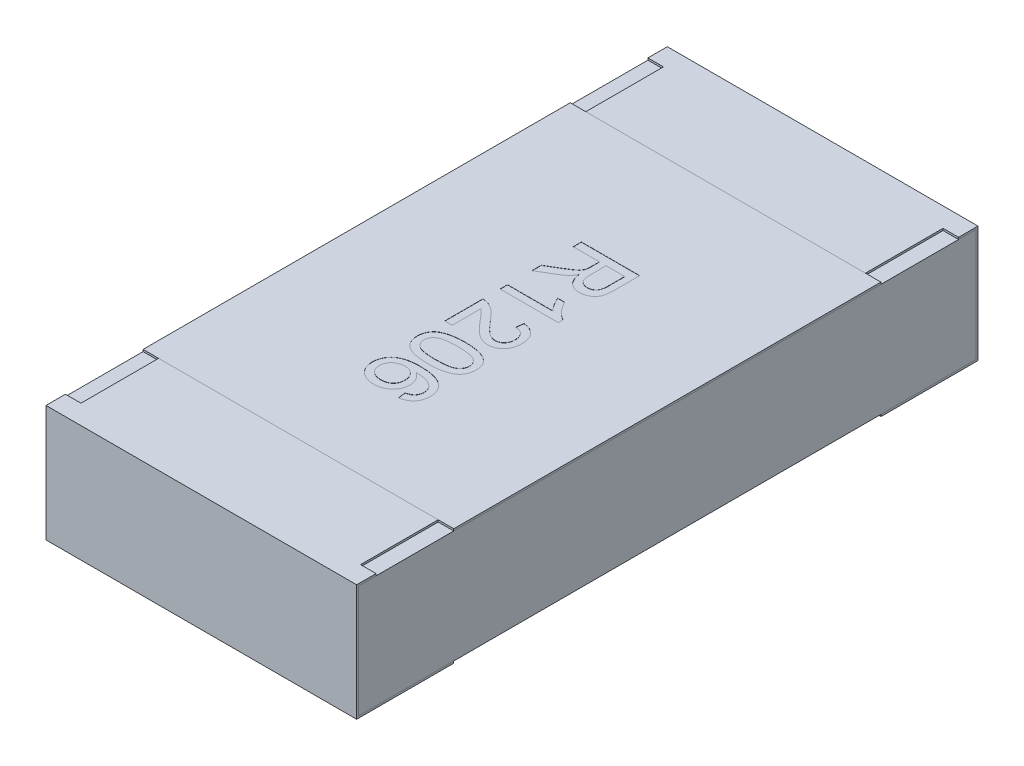
from build123d import *

# Parameters (mm, degrees)
BOSS_EXTRUDE2_DEPTH   = 0.8
BOSS_EXTRUDE2_2_DEPTH = 0.8
BOSS_EXTRUDE3_START   = -0.8
SKETCH5_W             = 3.18
SKETCH5_H             = 0.58
BOSS_EXTRUDE3_DEPTH   = 1.6
SKETCH6_W             = 0.08
SKETCH6_H             = 0.4
CUT_EXTRUDE1_DEPTH    = 0.01
SKETCH7_W             = 1.6
SKETCH7_H             = 2.2
BOSS_EXTRUDE4_DEPTH   = 0.01
TEXT1206_DEPTH        = 0.001


with BuildPart() as part:
    # Sketch4 → Boss-Extrude2 (new body, symmetric)
    with BuildSketch(Plane(origin=(0, 0, 0), x_dir=(0, 0, -1), z_dir=(1, 0, 0))):
        Polygon((-1.6, 0.3), (-1.6, -0.3), (-1.1, -0.3), (-1.1, -0.29), (-1.59, -0.29), (-1.59, 0.29), (-1.1, 0.29), (-1.1, 0.3), align=None)
    extrude(amount=BOSS_EXTRUDE2_DEPTH, both=True)


with BuildPart() as body_2:
    # Sketch4 → Boss-Extrude2 2 (new body, symmetric)
    with BuildSketch(Plane(origin=(0, 0, 0), x_dir=(0, 0, -1), z_dir=(1, 0, 0))):
        Polygon((1.1, 0.3), (1.6, 0.3), (1.6, -0.3), (1.1, -0.3), (1.1, -0.29), (1.59, -0.29), (1.59, 0.29), (1.1, 0.29), align=None)
    extrude(amount=BOSS_EXTRUDE2_2_DEPTH, both=True)


with BuildPart() as body_3:
    # Sketch5 → Boss-Extrude3 (new body)
    with BuildSketch(Plane(origin=(0, 0, 0), x_dir=(0, 0, -1), z_dir=(1, 0, 0)).offset(BOSS_EXTRUDE3_START)):
        Rectangle(SKETCH5_W, SKETCH5_H)
    extrude(amount=BOSS_EXTRUDE3_DEPTH)


with BuildPart() as cut_extrude1_tool:
    # Sketch6 → Cut-Extrude1 (new body)
    with BuildSketch(Plane(origin=(0, 0.3, 0), x_dir=(1, 0, 0), z_dir=(0, 1, 0))):
        with Locations((-0.76, 1.3)):
            Rectangle(SKETCH6_W, SKETCH6_H)
        with Locations((0.76, 1.3)):
            Rectangle(SKETCH6_W, SKETCH6_H)
        with Locations((0.76, -1.3)):
            Rectangle(SKETCH6_W, SKETCH6_H)
        with Locations((-0.76, -1.3)):
            Rectangle(SKETCH6_W, SKETCH6_H)
    extrude(amount=-CUT_EXTRUDE1_DEPTH)


with BuildPart() as part_1:
    add(part.part)

    # Cut-Extrude1: cut by cut_extrude1_tool
    add(cut_extrude1_tool.part, mode=Mode.SUBTRACT)


with BuildPart() as body_2_1:
    add(body_2.part)

    # Cut-Extrude1: cut by cut_extrude1_tool
    add(cut_extrude1_tool.part, mode=Mode.SUBTRACT)


with BuildPart() as body_4:
    # Sketch7 → Boss-Extrude4 (new body)
    with BuildSketch(Plane(origin=(0, 0.29, 0), x_dir=(1, 0, 0), z_dir=(0, 1, 0))):
        Rectangle(SKETCH7_W, SKETCH7_H)
    extrude(amount=BOSS_EXTRUDE4_DEPTH)

    # Sketch12 → TEXT1206 (cut)
    with BuildSketch(Plane(origin=(0, 0.3, 0), x_dir=(1, 0, 0), z_dir=(0, 1, 0))):
        with BuildLine():
            Line((-0.15, 0.507688704), (0.15, 0.507688704))
            Line((0.15, 0.507688704), (0.15, 0.377520435))
            add(Edge.make_bspline(
                [(0.15, 0.377520435), (0.149976098, 0.374455356), (0.149929838, 0.368523255), (0.149599275, 0.359920721), (0.148896994, 0.351910091), (0.148112632, 0.344440878), (0.146954506, 0.337525862), (0.145595815, 0.331161748), (0.14399, 0.325372947), (0.142091864, 0.320115402), (0.139945096, 0.315237172), (0.137294925, 0.310716634), (0.134395694, 0.306360041), (0.130961971, 0.302339737), (0.12726979, 0.29847974), (0.123136626, 0.294911955), (0.118620847, 0.29161897), (0.112164906, 0.28755572), (0.103522968, 0.283280255), (0.092520499, 0.279631156), (0.080987257, 0.277298105), (0.073108187, 0.277046918), (0.069110577, 0.276919473)],
                knots=[0, 0, 0, 0, 9.195e-06, 1.7797e-05, 2.5817e-05, 3.3316e-05, 4.0321e-05, 4.6839e-05, 5.2832e-05, 5.8326e-05, 6.3598e-05, 6.8794e-05, 7.4028e-05, 7.9275e-05, 8.463e-05, 9.0041e-05, 9.563e-05, 0.000101382, 0.000112912, 0.000124447, 0.00013608, 0.000148061, 0.000148061, 0.000148061, 0.000148061], degree=3))
            add(Edge.make_bspline(
                [(0.069110577, 0.276919473), (0.066544329, 0.276978179), (0.061475814, 0.277094125), (0.054023732, 0.277982277), (0.046903597, 0.27958935), (0.040052911, 0.281649992), (0.033569258, 0.284470798), (0.027318263, 0.287737107), (0.021478898, 0.291789228), (0.015856738, 0.296313931), (0.010702727, 0.301574208), (0.00594759, 0.30742974), (0.001839276, 0.314027897), (-0.001852779, 0.321247263), (-0.005083582, 0.329100938), (-0.007800008, 0.337641146), (-0.009926689, 0.346837648), (-0.010991982, 0.353215196), (-0.011538462, 0.356486781)],
                knots=[0, 0, 0, 0, 7.698e-06, 1.5204e-05, 2.2466e-05, 2.9575e-05, 3.663e-05, 4.3647e-05, 5.0697e-05, 5.7915e-05, 6.5267e-05, 7.2747e-05, 8.05e-05, 8.8536e-05, 9.7051e-05, 0.000105946, 0.000115392, 0.000125341, 0.000125341, 0.000125341, 0.000125341], degree=3))
            add(Edge.make_bspline(
                [(-0.011538462, 0.356486781), (-0.012753772, 0.35406856), (-0.01505392, 0.349491732), (-0.018746634, 0.343178787), (-0.022400996, 0.337757739), (-0.025073191, 0.334630892), (-0.026322115, 0.333169473)],
                knots=[0, 0, 0, 0, 8.117e-06, 1.5363e-05, 2.1931e-05, 2.7694e-05, 2.7694e-05, 2.7694e-05, 2.7694e-05], degree=3))
            add(Edge.make_bspline(
                [(-0.026322115, 0.333169473), (-0.029096413, 0.330330674), (-0.034786041, 0.324508765), (-0.044567018, 0.31656401), (-0.055323294, 0.308702769), (-0.06316159, 0.303983044), (-0.0671875, 0.301558896)],
                knots=[0, 0, 0, 0, 1.1899e-05, 2.4402e-05, 3.7746e-05, 5.1837e-05, 5.1837e-05, 5.1837e-05, 5.1837e-05], degree=3))
            Line((-0.0671875, 0.301558896), (-0.15, 0.252340146))
            Line((-0.15, 0.252340146), (-0.15, 0.300837743))
            Line((-0.15, 0.300837743), (-0.086658654, 0.33821755))
            add(Edge.make_bspline(
                [(-0.086658654, 0.33821755), (-0.084436284, 0.339561596), (-0.080129696, 0.342166135), (-0.073839518, 0.345927393), (-0.068050631, 0.349618517), (-0.062587585, 0.353030789), (-0.057592425, 0.356346736), (-0.052916134, 0.359380146), (-0.048743568, 0.362364404), (-0.043718189, 0.365835136), (-0.038248453, 0.370019606), (-0.03266463, 0.374935646), (-0.028105288, 0.379497197), (-0.02370073, 0.385204319), (-0.019596578, 0.392286081), (-0.017689234, 0.398293218), (-0.016766827, 0.401198319)],
                knots=[0, 0, 0, 0, 7.792e-06, 1.5099e-05, 2.1985e-05, 2.8387e-05, 3.4421e-05, 3.9972e-05, 4.5107e-05, 4.9808e-05, 5.8294e-05, 6.5746e-05, 7.212e-05, 7.7602e-05, 8.7344e-05, 9.6468e-05, 9.6468e-05, 9.6468e-05, 9.6468e-05], degree=3))
            add(Edge.make_bspline(
                [(-0.016766827, 0.401198319), (-0.016546925, 0.402417733), (-0.016044883, 0.405201691), (-0.015716998, 0.409928844), (-0.015368993, 0.415656371), (-0.015379133, 0.419807207), (-0.015384615, 0.422051685)],
                knots=[0, 0, 0, 0, 3.715e-06, 8.481e-06, 1.4198e-05, 2.0929e-05, 2.0929e-05, 2.0929e-05, 2.0929e-05], degree=3))
            Line((-0.015384615, 0.422051685), (-0.015384615, 0.465381012))
            Line((-0.015384615, 0.465381012), (-0.15, 0.465381012))
            Line((-0.15, 0.465381012), (-0.15, 0.507688704))
        make_face()
        with BuildLine():
            Line((0.019230769, 0.465381012), (0.019230769, 0.385032454))
            add(Edge.make_bspline(
                [(0.019230769, 0.385032454), (0.019294059, 0.381003526), (0.019412374, 0.373471823), (0.020415568, 0.36293915), (0.022027239, 0.353946653), (0.02434032, 0.346326486), (0.027566204, 0.339927885), (0.031574247, 0.334430884), (0.036450959, 0.329754481), (0.042058536, 0.325932572), (0.048176988, 0.322922341), (0.054649472, 0.320867375), (0.061335975, 0.319435692), (0.06589779, 0.31929729), (0.068209135, 0.319227166)],
                knots=[0, 0, 0, 0, 1.2085e-05, 2.2591e-05, 3.1702e-05, 3.9457e-05, 4.6391e-05, 5.3098e-05, 5.9771e-05, 6.6555e-05, 7.3382e-05, 8.0147e-05, 8.6889e-05, 9.3813e-05, 9.3813e-05, 9.3813e-05, 9.3813e-05], degree=3))
            add(Edge.make_bspline(
                [(0.068209135, 0.319227166), (0.069893078, 0.319283004), (0.073191429, 0.319392375), (0.078032493, 0.319965732), (0.082632622, 0.321080474), (0.087016134, 0.322552489), (0.091150922, 0.3245194), (0.095069027, 0.32685601), (0.098748733, 0.329644306), (0.102201249, 0.33283814), (0.1053427, 0.336505241), (0.108053092, 0.340693932), (0.11035634, 0.345371178), (0.112184352, 0.350542415), (0.113646463, 0.356191353), (0.114619159, 0.36235015), (0.115322998, 0.36899064), (0.115363693, 0.373592114), (0.115384615, 0.375957935)],
                knots=[0, 0, 0, 0, 5.054e-06, 9.899e-06, 1.4593e-05, 1.923e-05, 2.3746e-05, 2.8302e-05, 3.2893e-05, 3.757e-05, 4.2387e-05, 4.7338e-05, 5.2498e-05, 5.7992e-05, 6.3764e-05, 6.9978e-05, 7.6682e-05, 8.3775e-05, 8.3775e-05, 8.3775e-05, 8.3775e-05], degree=3))
            Line((0.115384615, 0.375957935), (0.115384615, 0.465381012))
            Line((0.115384615, 0.465381012), (0.019230769, 0.465381012))
        make_face(mode=Mode.SUBTRACT)
        with BuildLine():
            Line((-0.15, 0.088457935), (-0.15, 0.126919473))
            Line((-0.15, 0.126919473), (0.083774038, 0.126919473))
            add(Edge.make_bspline(
                [(0.083774038, 0.126919473), (0.081638509, 0.129134219), (0.077200045, 0.133737325), (0.070914564, 0.141515786), (0.064571645, 0.150195638), (0.058389404, 0.159632893), (0.052683492, 0.169326831), (0.047476916, 0.178666395), (0.043093554, 0.187521136), (0.040694469, 0.193352207), (0.039543269, 0.196150243)],
                knots=[0, 0, 0, 0, 9.226e-06, 1.9175e-05, 2.9969e-05, 4.147e-05, 5.3003e-05, 6.3709e-05, 7.3546e-05, 8.262e-05, 8.262e-05, 8.262e-05, 8.262e-05], degree=3))
            Line((0.039543269, 0.196150243), (0.075, 0.196150243))
            add(Edge.make_bspline(
                [(0.075, 0.196150243), (0.077475162, 0.191344122), (0.082353558, 0.181871544), (0.09077922, 0.168488839), (0.099912985, 0.155994644), (0.10975283, 0.144595788), (0.119810917, 0.13437744), (0.129959923, 0.12576629), (0.139827828, 0.118561027), (0.146709597, 0.11494601), (0.15, 0.11321755)],
                knots=[0, 0, 0, 0, 1.6212e-05, 3.1953e-05, 4.7386e-05, 6.26e-05, 7.7091e-05, 9.0349e-05, 0.000102505, 0.000113642, 0.000113642, 0.000113642, 0.000113642], degree=3))
            Line((0.15, 0.11321755), (0.15, 0.088457935))
            Line((0.15, 0.088457935), (-0.15, 0.088457935))
        make_face()
        with BuildLine():
            Line((-0.111538462, -0.19615745), (-0.15, -0.19615745))
            Line((-0.15, -0.19615745), (-0.15, -3.604e-06))
            add(Edge.make_bspline(
                [(-0.15, -3.604e-06), (-0.147714123, 4.12e-07), (-0.14315003, 8.43e-06), (-0.136400026, -0.000763888), (-0.129739566, -0.001973492), (-0.125468478, -0.003341192), (-0.123317308, -0.004030046)],
                knots=[0, 0, 0, 0, 6.852e-06, 1.3681e-05, 2.0352e-05, 2.7121e-05, 2.7121e-05, 2.7121e-05, 2.7121e-05], degree=3))
            add(Edge.make_bspline(
                [(-0.123317308, -0.004030046), (-0.119803316, -0.005304062), (-0.112648251, -0.00789817), (-0.102300861, -0.013133764), (-0.092077121, -0.019394304), (-0.083693742, -0.025385777), (-0.077044802, -0.03090393), (-0.071780052, -0.035454388), (-0.066458477, -0.040580386), (-0.06098519, -0.04618848), (-0.055359875, -0.052244636), (-0.049556317, -0.058748619), (-0.043684824, -0.065779698), (-0.039792869, -0.070688025), (-0.037800481, -0.073200719)],
                knots=[0, 0, 0, 0, 1.1205e-05, 2.2816e-05, 3.4709e-05, 4.7152e-05, 5.3684e-05, 6.0627e-05, 6.8023e-05, 7.5842e-05, 8.4134e-05, 9.2818e-05, 0.00010199, 0.00011161, 0.00011161, 0.00011161, 0.00011161], degree=3))
            add(Edge.make_bspline(
                [(-0.037800481, -0.073200719), (-0.034551471, -0.077060851), (-0.028295295, -0.084493779), (-0.019011711, -0.094990239), (-0.010391377, -0.104577047), (-0.002283205, -0.113101543), (0.005234162, -0.120633449), (0.012143692, -0.127190451), (0.018423822, -0.132828966), (0.024301865, -0.137480159), (0.029852373, -0.141404514), (0.035266551, -0.144730057), (0.040638972, -0.147501457), (0.045952637, -0.149809662), (0.05123027, -0.151635256), (0.056487246, -0.152879658), (0.061671403, -0.153723569), (0.065120999, -0.153808002), (0.066826923, -0.153849757)],
                knots=[0, 0, 0, 0, 1.5136e-05, 2.9145e-05, 4.2036e-05, 5.3811e-05, 6.4435e-05, 7.3957e-05, 8.2386e-05, 8.9745e-05, 9.643e-05, 0.000102769, 0.00010879, 0.00011455, 0.000120137, 0.000125516, 0.000130743, 0.000135857, 0.000135857, 0.000135857, 0.000135857], degree=3))
            add(Edge.make_bspline(
                [(0.066826923, -0.153849757), (0.068512943, -0.153807997), (0.071820821, -0.153726067), (0.076661881, -0.152948711), (0.081323937, -0.151866569), (0.085723062, -0.150117074), (0.089989535, -0.148034651), (0.093988521, -0.145363433), (0.097819766, -0.14227341), (0.101381944, -0.138735493), (0.104724786, -0.134871644), (0.107500012, -0.130552892), (0.110020859, -0.126053378), (0.111988045, -0.121224393), (0.113504097, -0.116108944), (0.114560258, -0.110715235), (0.115243078, -0.105028866), (0.115336721, -0.101147443), (0.115384615, -0.099162257)],
                knots=[0, 0, 0, 0, 5.054e-06, 9.915e-06, 1.4681e-05, 1.938e-05, 2.4083e-05, 2.89e-05, 3.3772e-05, 3.8829e-05, 4.3946e-05, 4.9063e-05, 5.4199e-05, 5.94e-05, 6.4667e-05, 7.0183e-05, 7.587e-05, 8.1825e-05, 8.1825e-05, 8.1825e-05, 8.1825e-05], degree=3))
            add(Edge.make_bspline(
                [(0.115384615, -0.099162257), (0.115336639, -0.097076994), (0.115242746, -0.092995979), (0.114561705, -0.087029984), (0.113515033, -0.08136873), (0.111941815, -0.076032409), (0.109882187, -0.071031693), (0.10742732, -0.06633113), (0.104518024, -0.061948695), (0.101139001, -0.057954518), (0.097458268, -0.054254667), (0.093296561, -0.051129106), (0.088872885, -0.048396939), (0.084046797, -0.046241606), (0.078924308, -0.044483863), (0.073429376, -0.043215118), (0.067585566, -0.042521691), (0.063583419, -0.042382445), (0.061538462, -0.042311296)],
                knots=[0, 0, 0, 0, 6.255e-06, 1.2241e-05, 1.7992e-05, 2.3507e-05, 2.8897e-05, 3.4193e-05, 3.9393e-05, 4.4641e-05, 4.9868e-05, 5.5012e-05, 6.0217e-05, 6.5434e-05, 7.0832e-05, 7.6444e-05, 8.2318e-05, 8.8455e-05, 8.8455e-05, 8.8455e-05, 8.8455e-05], degree=3))
            Line((0.061538462, -0.042311296), (0.065384615, -0.003849757))
            add(Edge.make_bspline(
                [(0.065384615, -0.003849757), (0.068736662, -0.004243232), (0.07525778, -0.005008704), (0.084702032, -0.006916159), (0.093489714, -0.009591228), (0.101734943, -0.012801739), (0.109336857, -0.016797101), (0.116323186, -0.021428959), (0.122725854, -0.026693701), (0.12839596, -0.032683007), (0.133571363, -0.03916764), (0.137925688, -0.046308459), (0.141698648, -0.05393981), (0.144749435, -0.062116004), (0.147087025, -0.070833834), (0.148758415, -0.080079721), (0.149789925, -0.089864131), (0.149928976, -0.096575555), (0.15, -0.100003604)],
                knots=[0, 0, 0, 0, 1.0123e-05, 1.9693e-05, 2.8857e-05, 3.7651e-05, 4.6199e-05, 5.4566e-05, 6.276e-05, 7.1006e-05, 7.9266e-05, 8.7604e-05, 9.6043e-05, 0.000104772, 0.000113738, 0.000123085, 0.000132934, 0.000143217, 0.000143217, 0.000143217, 0.000143217], degree=3))
            add(Edge.make_bspline(
                [(0.15, -0.100003604), (0.149940576, -0.103472658), (0.149824817, -0.110230395), (0.148641062, -0.120077687), (0.146795931, -0.129368199), (0.144229333, -0.138139118), (0.140839664, -0.146343844), (0.136757117, -0.154010468), (0.131911514, -0.161114716), (0.126324053, -0.167560142), (0.120221623, -0.173372561), (0.113705953, -0.178458814), (0.106829733, -0.182734888), (0.099612825, -0.186271787), (0.092008541, -0.188980024), (0.084045391, -0.190864772), (0.075742745, -0.192151321), (0.070077161, -0.192257262), (0.0671875, -0.192311296)],
                knots=[0, 0, 0, 0, 1.0403e-05, 2.0265e-05, 2.9705e-05, 3.8794e-05, 4.7633e-05, 5.6291e-05, 6.4808e-05, 7.3373e-05, 8.1833e-05, 9.0055e-05, 9.8126e-05, 0.000106082, 0.000114122, 0.000122285, 0.000130605, 0.000139266, 0.000139266, 0.000139266, 0.000139266], degree=3))
            add(Edge.make_bspline(
                [(0.0671875, -0.192311296), (0.064218398, -0.192230182), (0.05827364, -0.192067776), (0.049399233, -0.190752501), (0.040594357, -0.188635306), (0.03178904, -0.185697536), (0.02297561, -0.18160909), (0.013942435, -0.176573846), (0.004756402, -0.170280475), (-0.003111225, -0.164312224), (-0.009660413, -0.15869296), (-0.015062592, -0.153712157), (-0.020824791, -0.147951079), (-0.027059821, -0.141562927), (-0.033675497, -0.134416862), (-0.04077151, -0.126643103), (-0.048197577, -0.11808725), (-0.053269547, -0.112146671), (-0.055889423, -0.109078123)],
                knots=[0, 0, 0, 0, 8.904e-06, 1.7828e-05, 2.6851e-05, 3.6049e-05, 4.5623e-05, 5.5954e-05, 6.7039e-05, 7.8998e-05, 8.5562e-05, 9.292e-05, 0.000101036, 0.000110004, 0.000119698, 0.000130249, 0.000141579, 0.000153683, 0.000153683, 0.000153683, 0.000153683], degree=3))
            add(Edge.make_bspline(
                [(-0.055889423, -0.109078123), (-0.058028577, -0.106450425), (-0.062107615, -0.101439811), (-0.068021764, -0.094311811), (-0.073442596, -0.087925321), (-0.07820298, -0.082139486), (-0.082492694, -0.077150347), (-0.086224809, -0.072850896), (-0.089451821, -0.069283824), (-0.094402484, -0.063846006), (-0.10140021, -0.056906337), (-0.108253196, -0.051834189), (-0.111538462, -0.049402642)],
                knots=[0, 0, 0, 0, 1.0165e-05, 1.9383e-05, 2.7786e-05, 3.5295e-05, 4.1859e-05, 4.7524e-05, 5.2375e-05, 5.6288e-05, 6.9591e-05, 8.184e-05, 8.184e-05, 8.184e-05, 8.184e-05], degree=3))
            Line((-0.111538462, -0.049402642), (-0.111538462, -0.19615745))
        make_face()
        with BuildLine():
            add(Edge.make_bspline(
                [(-0.002043269, -0.238465142), (0.002244006, -0.238503892), (0.010640973, -0.238579787), (0.022927245, -0.239050538), (0.034595007, -0.239872434), (0.045634132, -0.241099292), (0.05606952, -0.242552142), (0.065886336, -0.244440782), (0.075106414, -0.246566023), (0.083720798, -0.249115066), (0.091801288, -0.251918562), (0.099342803, -0.255088919), (0.106300734, -0.25868735), (0.112864039, -0.26238937), (0.118725274, -0.266699469), (0.12425569, -0.271070427), (0.129139599, -0.275949288), (0.133536862, -0.281104008), (0.137415967, -0.286620019), (0.140763485, -0.292465637), (0.143719015, -0.298619035), (0.145943958, -0.305197309), (0.147757752, -0.312063945), (0.149092003, -0.319271784), (0.149878588, -0.326828774), (0.149959072, -0.331992915), (0.15, -0.334618988)],
                knots=[0, 0, 0, 0, 1.2862e-05, 2.5191e-05, 3.688e-05, 4.7943e-05, 5.8507e-05, 6.8478e-05, 7.7924e-05, 8.6881e-05, 9.5415e-05, 0.000103574, 0.000111395, 0.000118909, 0.000126147, 0.000133195, 0.000140037, 0.000146816, 0.000153502, 0.000160233, 0.000167008, 0.000173945, 0.000181029, 0.000188302, 0.000195914, 0.00020379, 0.00020379, 0.00020379, 0.00020379], degree=3))
            add(Edge.make_bspline(
                [(0.15, -0.334618988), (0.149886629, -0.338471711), (0.149663908, -0.346040538), (0.147850494, -0.357092241), (0.144740696, -0.367503285), (0.140578188, -0.377272041), (0.135193656, -0.386187278), (0.128816305, -0.394247482), (0.121179131, -0.401126985), (0.11253276, -0.407053036), (0.102860028, -0.412134623), (0.092252026, -0.416680312), (0.080663785, -0.420755945), (0.070320072, -0.423739131), (0.061375886, -0.425830609), (0.053985027, -0.427103959), (0.046034731, -0.428279631), (0.03750596, -0.429112963), (0.028438575, -0.429960946), (0.018793038, -0.430379605), (0.008575899, -0.430699104), (0.001562812, -0.430747797), (-0.002043269, -0.430772834)],
                knots=[0, 0, 0, 0, 1.1554e-05, 2.2698e-05, 3.348e-05, 4.4085e-05, 5.4464e-05, 6.4638e-05, 7.4805e-05, 8.5173e-05, 9.6008e-05, 0.000107529, 0.00011977, 0.000132837, 0.000139806, 0.000147315, 0.000155329, 0.00016391, 0.000173019, 0.000182646, 0.000192867, 0.000203685, 0.000203685, 0.000203685, 0.000203685], degree=3))
            add(Edge.make_bspline(
                [(-0.002043269, -0.430772834), (-0.00631044, -0.430733577), (-0.014647199, -0.43065688), (-0.026834487, -0.430195707), (-0.03841587, -0.429334972), (-0.049405471, -0.428225788), (-0.059813481, -0.426732412), (-0.069614428, -0.424865865), (-0.078820333, -0.422709999), (-0.087440482, -0.420270342), (-0.095486737, -0.417431979), (-0.102997606, -0.414230679), (-0.110046684, -0.410797941), (-0.116502689, -0.406904283), (-0.122472492, -0.402757306), (-0.127974887, -0.398318266), (-0.132931669, -0.393495216), (-0.137314485, -0.38829238), (-0.141263346, -0.382815746), (-0.144641302, -0.376954937), (-0.147459366, -0.370723663), (-0.149814671, -0.364177459), (-0.151604655, -0.357272877), (-0.15293367, -0.350045891), (-0.153727476, -0.342449353), (-0.153806049, -0.337265122), (-0.153846154, -0.334618988)],
                knots=[0, 0, 0, 0, 1.2802e-05, 2.5011e-05, 3.658e-05, 4.7637e-05, 5.8141e-05, 6.8112e-05, 7.7558e-05, 8.6498e-05, 9.4975e-05, 0.000103135, 0.000110983, 0.000118475, 0.000125727, 0.000132776, 0.000139661, 0.00014644, 0.00015316, 0.000159891, 0.000166695, 0.000173652, 0.000180737, 0.000188068, 0.000195681, 0.000203617, 0.000203617, 0.000203617, 0.000203617], degree=3))
            add(Edge.make_bspline(
                [(-0.153846154, -0.334618988), (-0.153747192, -0.331149678), (-0.153554242, -0.324385479), (-0.152243272, -0.314506865), (-0.149935902, -0.305235258), (-0.146841394, -0.296492459), (-0.142702311, -0.288376739), (-0.137666308, -0.280849347), (-0.131850554, -0.273759028), (-0.127262057, -0.269677409), (-0.124939904, -0.267611777)],
                knots=[0, 0, 0, 0, 1.0408e-05, 2.0292e-05, 2.9825e-05, 3.9025e-05, 4.8056e-05, 5.7073e-05, 6.616e-05, 7.5471e-05, 7.5471e-05, 7.5471e-05, 7.5471e-05], degree=3))
            add(Edge.make_bspline(
                [(-0.124939904, -0.267611777), (-0.121510195, -0.265234187), (-0.11443799, -0.260331494), (-0.102379223, -0.254593318), (-0.089104214, -0.249474763), (-0.074352508, -0.245457636), (-0.058241513, -0.242311224), (-0.040739616, -0.240038729), (-0.021854376, -0.238752721), (-0.008796046, -0.238563166), (-0.002043269, -0.238465142)],
                knots=[0, 0, 0, 0, 1.2501e-05, 2.5778e-05, 3.993e-05, 5.5152e-05, 7.157e-05, 8.9147e-05, 0.000108063, 0.000128321, 0.000128321, 0.000128321, 0.000128321], degree=3))
        make_face()
        with BuildLine():
            add(Edge.make_bspline(
                [(-0.001923077, -0.276926681), (-0.007693168, -0.27696487), (-0.018738399, -0.277037972), (-0.034518417, -0.277801718), (-0.048754147, -0.279116474), (-0.061425879, -0.280854668), (-0.072550754, -0.283149788), (-0.082100422, -0.286031582), (-0.090189501, -0.289280049), (-0.096717734, -0.293299966), (-0.102039196, -0.297701331), (-0.106615825, -0.302245439), (-0.110505855, -0.307039198), (-0.113749347, -0.312051329), (-0.116205105, -0.3173596), (-0.117985045, -0.322905963), (-0.119009373, -0.328691628), (-0.119156549, -0.332631928), (-0.119230769, -0.334618988)],
                knots=[0, 0, 0, 0, 1.7309e-05, 3.3134e-05, 4.7378e-05, 6.0186e-05, 7.1489e-05, 8.1413e-05, 9.0085e-05, 9.7558e-05, 0.000104306, 0.000110765, 0.000116876, 0.000122794, 0.000128628, 0.000134368, 0.000140227, 0.000146187, 0.000146187, 0.000146187, 0.000146187], degree=3))
            add(Edge.make_bspline(
                [(-0.119230769, -0.334618988), (-0.119154928, -0.336605551), (-0.119004535, -0.340544864), (-0.118002795, -0.346343897), (-0.116131225, -0.351868681), (-0.11368414, -0.357169037), (-0.110514577, -0.362217598), (-0.106609854, -0.366987813), (-0.102035942, -0.371555859), (-0.096652628, -0.375937453), (-0.090094213, -0.379926744), (-0.082011723, -0.383236148), (-0.072445331, -0.386073031), (-0.061326124, -0.388380745), (-0.048674427, -0.390126109), (-0.03447818, -0.391432916), (-0.018718466, -0.392201773), (-0.007693194, -0.392273669), (-0.001923077, -0.392311296)],
                knots=[0, 0, 0, 0, 5.96e-06, 1.1819e-05, 1.7578e-05, 2.3412e-05, 2.9298e-05, 3.5408e-05, 4.1867e-05, 4.8662e-05, 5.6186e-05, 6.4803e-05, 7.4784e-05, 8.6088e-05, 9.8836e-05, 0.00011308, 0.000128845, 0.000146154, 0.000146154, 0.000146154, 0.000146154], degree=3))
            add(Edge.make_bspline(
                [(-0.001923077, -0.392311296), (0.003726983, -0.392274874), (0.014552285, -0.392205091), (0.030028294, -0.391416398), (0.044025103, -0.390180476), (0.056555506, -0.388489839), (0.067606248, -0.386243268), (0.077199767, -0.383517621), (0.085318952, -0.38027225), (0.09203502, -0.376405367), (0.097578912, -0.372117892), (0.102284051, -0.367562559), (0.106407321, -0.362827524), (0.109635927, -0.3576422), (0.11228385, -0.352227021), (0.114056455, -0.346465905), (0.1151941, -0.34043324), (0.115320181, -0.336307021), (0.115384615, -0.334198315)],
                knots=[0, 0, 0, 0, 1.6949e-05, 3.2473e-05, 4.6473e-05, 5.9094e-05, 7.0385e-05, 8.0274e-05, 8.8979e-05, 9.6545e-05, 0.000103444, 0.000109947, 0.000116172, 0.000122224, 0.000128218, 0.000134205, 0.000140252, 0.000146573, 0.000146573, 0.000146573, 0.000146573], degree=3))
            add(Edge.make_bspline(
                [(0.115384615, -0.334198315), (0.115332466, -0.33221138), (0.115229635, -0.328293398), (0.114248109, -0.32255696), (0.112606778, -0.317120605), (0.110383437, -0.31192205), (0.107391258, -0.307091074), (0.103897677, -0.302436093), (0.099641138, -0.298175128), (0.096459016, -0.295607508), (0.094831731, -0.294294469)],
                knots=[0, 0, 0, 0, 5.957e-06, 1.1747e-05, 1.7393e-05, 2.2965e-05, 2.8654e-05, 3.4399e-05, 4.0391e-05, 4.6662e-05, 4.6662e-05, 4.6662e-05, 4.6662e-05], degree=3))
            add(Edge.make_bspline(
                [(0.094831731, -0.294294469), (0.092441753, -0.29286497), (0.087394622, -0.289846169), (0.078622501, -0.286468306), (0.068597636, -0.283484436), (0.057165788, -0.281027721), (0.044346567, -0.27925046), (0.03015486, -0.277847382), (0.014570853, -0.277118534), (0.003726591, -0.276992396), (-0.001923077, -0.276926681)],
                knots=[0, 0, 0, 0, 8.341e-06, 1.7615e-05, 2.8091e-05, 3.9714e-05, 5.2649e-05, 6.6899e-05, 8.2483e-05, 9.9433e-05, 9.9433e-05, 9.9433e-05, 9.9433e-05], degree=3))
        make_face(mode=Mode.SUBTRACT)
        with BuildLine():
            Line((0.073076923, -0.657695911), (0.069230769, -0.619234373))
            add(Edge.make_bspline(
                [(0.069230769, -0.619234373), (0.072538667, -0.618404404), (0.078765275, -0.616842115), (0.087210729, -0.613566009), (0.094354147, -0.609955811), (0.09820068, -0.606819333), (0.1, -0.605352161)],
                knots=[0, 0, 0, 0, 1.022e-05, 1.9238e-05, 2.7142e-05, 3.4089e-05, 3.4089e-05, 3.4089e-05, 3.4089e-05], degree=3))
            add(Edge.make_bspline(
                [(0.1, -0.605352161), (0.101227235, -0.604092765), (0.103640922, -0.601615823), (0.10678718, -0.597549587), (0.109452847, -0.593263101), (0.111612442, -0.588743409), (0.113318398, -0.58401493), (0.114511805, -0.579058076), (0.115250592, -0.573884077), (0.115339561, -0.570358643), (0.115384615, -0.568573315)],
                knots=[0, 0, 0, 0, 5.272e-06, 1.0369e-05, 1.5389e-05, 2.0388e-05, 2.5369e-05, 3.0441e-05, 3.5659e-05, 4.1013e-05, 4.1013e-05, 4.1013e-05, 4.1013e-05], degree=3))
            add(Edge.make_bspline(
                [(0.115384615, -0.568573315), (0.115291422, -0.565678991), (0.115107275, -0.559959932), (0.113304494, -0.551569051), (0.110606344, -0.543419146), (0.107871213, -0.538369979), (0.106490385, -0.535820911)],
                knots=[0, 0, 0, 0, 8.671e-06, 1.7133e-05, 2.5647e-05, 3.4328e-05, 3.4328e-05, 3.4328e-05, 3.4328e-05], degree=3))
            add(Edge.make_bspline(
                [(0.106490385, -0.535820911), (0.10441265, -0.533315216), (0.100147558, -0.528171622), (0.092289965, -0.521444406), (0.083077394, -0.515521446), (0.074540242, -0.511066362), (0.066846581, -0.507976489), (0.060290972, -0.505863883), (0.053006364, -0.504168663), (0.045063657, -0.502725186), (0.036435089, -0.501617964), (0.027119809, -0.500689631), (0.017092814, -0.500176835), (0.01017678, -0.500062539), (0.006610577, -0.500003604)],
                knots=[0, 0, 0, 0, 9.752e-06, 2.0019e-05, 3.087e-05, 4.2561e-05, 4.8844e-05, 5.5724e-05, 6.3202e-05, 7.1264e-05, 7.9934e-05, 8.9292e-05, 9.9343e-05, 0.000110043, 0.000110043, 0.000110043, 0.000110043], degree=3))
            add(Edge.make_bspline(
                [(0.006610577, -0.500003604), (0.009795477, -0.502271924), (0.016030114, -0.506712298), (0.024212744, -0.514543064), (0.031067161, -0.523146753), (0.036597117, -0.532428699), (0.04084587, -0.542183845), (0.043940923, -0.552195493), (0.045813696, -0.562473528), (0.046039886, -0.569406997), (0.046153846, -0.572900238)],
                knots=[0, 0, 0, 0, 1.1719e-05, 2.294e-05, 3.3846e-05, 4.4627e-05, 5.5256e-05, 6.5692e-05, 7.6007e-05, 8.6481e-05, 8.6481e-05, 8.6481e-05, 8.6481e-05], degree=3))
            add(Edge.make_bspline(
                [(0.046153846, -0.572900238), (0.046073141, -0.575909033), (0.045913693, -0.581853478), (0.044642775, -0.590605657), (0.042443894, -0.598984755), (0.039510539, -0.607068782), (0.03561771, -0.614750771), (0.030986977, -0.622161115), (0.025382922, -0.629135209), (0.019081048, -0.63576637), (0.012076169, -0.641804357), (0.004536554, -0.647148251), (-0.003555427, -0.651601548), (-0.012145697, -0.655212646), (-0.021202967, -0.658038964), (-0.030752967, -0.660092619), (-0.040814567, -0.661294802), (-0.047693081, -0.66145854), (-0.051201923, -0.661542065)],
                knots=[0, 0, 0, 0, 9.024e-06, 1.7829e-05, 2.6458e-05, 3.4976e-05, 4.3576e-05, 5.2246e-05, 6.1144e-05, 7.0367e-05, 7.9656e-05, 8.8843e-05, 9.8042e-05, 0.000107306, 0.000116753, 0.000126465, 0.000136573, 0.000147098, 0.000147098, 0.000147098, 0.000147098], degree=3))
            add(Edge.make_bspline(
                [(-0.051201923, -0.661542065), (-0.055838732, -0.661391606), (-0.064989364, -0.661094679), (-0.078471794, -0.658735963), (-0.0914327, -0.654874373), (-0.101789083, -0.650443235), (-0.109589893, -0.646118592), (-0.115155958, -0.642645265), (-0.120335333, -0.638823262), (-0.125221374, -0.634777444), (-0.12965227, -0.630331398), (-0.133846599, -0.625740149), (-0.137559741, -0.620748713), (-0.14100293, -0.6155594), (-0.143981548, -0.610066115), (-0.146648405, -0.604422144), (-0.14887735, -0.598575121), (-0.150664912, -0.592540701), (-0.152128372, -0.586345954), (-0.15313727, -0.579958535), (-0.153758817, -0.573393556), (-0.153816816, -0.568955323), (-0.153846154, -0.566710334)],
                knots=[0, 0, 0, 0, 1.3904e-05, 2.744e-05, 4.0921e-05, 5.4406e-05, 6.1131e-05, 6.7667e-05, 7.4073e-05, 8.0429e-05, 8.6676e-05, 9.2889e-05, 9.9067e-05, 0.000105318, 0.000111558, 0.000117795, 0.000124034, 0.000130308, 0.000136664, 0.000143115, 0.000149693, 0.000156427, 0.000156427, 0.000156427, 0.000156427], degree=3))
            add(Edge.make_bspline(
                [(-0.153846154, -0.566710334), (-0.153740754, -0.562919066), (-0.153534047, -0.555483721), (-0.151953702, -0.544599194), (-0.149288315, -0.534252583), (-0.145633365, -0.524425866), (-0.140909903, -0.515140278), (-0.135075633, -0.506428024), (-0.12820275, -0.498251609), (-0.120287752, -0.490599479), (-0.111121362, -0.483686824), (-0.100618232, -0.47766056), (-0.088691171, -0.472724426), (-0.075489024, -0.468555262), (-0.060886894, -0.465468503), (-0.044979101, -0.46308794), (-0.027704336, -0.461835831), (-0.015746934, -0.461642285), (-0.009555288, -0.461542065)],
                knots=[0, 0, 0, 0, 1.1371e-05, 2.2301e-05, 3.2912e-05, 4.3371e-05, 5.3692e-05, 6.4092e-05, 7.4757e-05, 8.568e-05, 9.705e-05, 0.000109111, 0.000121902, 0.000135701, 0.000150589, 0.000166627, 0.000183925, 0.000202501, 0.000202501, 0.000202501, 0.000202501], degree=3))
            add(Edge.make_bspline(
                [(-0.009555288, -0.461542065), (-0.006029435, -0.461566242), (0.000923993, -0.461613921), (0.011166388, -0.461957328), (0.02104414, -0.462634447), (0.030544369, -0.463524462), (0.039682284, -0.464671204), (0.048451962, -0.466017292), (0.056841129, -0.467734704), (0.064868317, -0.469624354), (0.072539039, -0.47181649), (0.07986297, -0.474172209), (0.086786449, -0.476906242), (0.093351424, -0.47984066), (0.099548274, -0.483033805), (0.105400821, -0.486433229), (0.110833989, -0.490191004), (0.114237069, -0.492893534), (0.115925481, -0.494234373)],
                knots=[0, 0, 0, 0, 1.0578e-05, 2.086e-05, 3.0738e-05, 4.0276e-05, 4.9482e-05, 5.8364e-05, 6.6885e-05, 7.5165e-05, 8.3098e-05, 9.0813e-05, 9.8235e-05, 0.000105417, 0.000112378, 0.000119139, 0.000125707, 0.000132174, 0.000132174, 0.000132174, 0.000132174], degree=3))
            add(Edge.make_bspline(
                [(0.115925481, -0.494234373), (0.118650597, -0.496657123), (0.124022054, -0.501432587), (0.130960705, -0.509601906), (0.136887379, -0.518307003), (0.14167562, -0.527686715), (0.145408685, -0.537669351), (0.14811856, -0.548261171), (0.149690101, -0.559491729), (0.149895026, -0.567166109), (0.15, -0.571097354)],
                knots=[0, 0, 0, 0, 1.0928e-05, 2.154e-05, 3.2057e-05, 4.2459e-05, 5.3051e-05, 6.3969e-05, 7.5196e-05, 8.6987e-05, 8.6987e-05, 8.6987e-05, 8.6987e-05], degree=3))
            add(Edge.make_bspline(
                [(0.15, -0.571097354), (0.149948255, -0.574024602), (0.149846599, -0.579775416), (0.148871193, -0.588201828), (0.147240948, -0.596216826), (0.145041931, -0.603838262), (0.142114758, -0.611021819), (0.138645741, -0.617850316), (0.134472732, -0.624254414), (0.129652743, -0.630187751), (0.124322407, -0.635665023), (0.118436964, -0.64057094), (0.112069766, -0.644887016), (0.10520757, -0.648647004), (0.097882861, -0.651817303), (0.090064157, -0.654420277), (0.081753468, -0.656398711), (0.076009194, -0.657257517), (0.073076923, -0.657695911)],
                knots=[0, 0, 0, 0, 8.779e-06, 1.7247e-05, 2.5403e-05, 3.3295e-05, 4.1006e-05, 4.864e-05, 5.624e-05, 6.389e-05, 7.1539e-05, 7.9134e-05, 8.6834e-05, 9.458e-05, 0.000102574, 0.000110746, 0.000119273, 0.000128165, 0.000128165, 0.000128165, 0.000128165], degree=3))
        make_face()
        with BuildLine():
            add(Edge.make_bspline(
                [(-0.050420673, -0.500003604), (-0.053432194, -0.500110583), (-0.0594157, -0.500323137), (-0.068297189, -0.501948933), (-0.076962701, -0.504603973), (-0.085315996, -0.508242735), (-0.093077055, -0.512735936), (-0.099953889, -0.518072812), (-0.105845529, -0.52413752), (-0.110764759, -0.530897467), (-0.114545052, -0.538336786), (-0.117282967, -0.546322237), (-0.118937772, -0.55486336), (-0.119131628, -0.56075338), (-0.119230769, -0.563765623)],
                knots=[0, 0, 0, 0, 9.031e-06, 1.7943e-05, 2.6992e-05, 3.6169e-05, 4.5219e-05, 5.3826e-05, 6.2198e-05, 7.0505e-05, 7.881e-05, 8.7134e-05, 9.5761e-05, 0.000104792, 0.000104792, 0.000104792, 0.000104792], degree=3))
            add(Edge.make_bspline(
                [(-0.119230769, -0.563765623), (-0.119172977, -0.565912289), (-0.119060171, -0.570102393), (-0.118178429, -0.576235676), (-0.11684577, -0.58207564), (-0.114806117, -0.587594869), (-0.112309347, -0.592831805), (-0.10918855, -0.597760372), (-0.105531209, -0.602381911), (-0.101314299, -0.606646563), (-0.096625632, -0.610501392), (-0.091492468, -0.613850594), (-0.085999671, -0.616808288), (-0.080012146, -0.619032938), (-0.073683317, -0.620845708), (-0.066953335, -0.62217844), (-0.059814476, -0.622960893), (-0.05490983, -0.623040071), (-0.052403846, -0.623080527)],
                knots=[0, 0, 0, 0, 6.437e-06, 1.2565e-05, 1.8556e-05, 2.4373e-05, 3.0179e-05, 3.5931e-05, 4.1835e-05, 4.7827e-05, 5.389e-05, 6.0007e-05, 6.619e-05, 7.2563e-05, 7.9125e-05, 8.5926e-05, 9.312e-05, 0.000100636, 0.000100636, 0.000100636, 0.000100636], degree=3))
            add(Edge.make_bspline(
                [(-0.052403846, -0.623080527), (-0.049997405, -0.623042969), (-0.045291307, -0.622969521), (-0.038423791, -0.62214436), (-0.031932743, -0.620939796), (-0.025867365, -0.61909957), (-0.020191383, -0.61681479), (-0.014868585, -0.614061111), (-0.009963369, -0.610736021), (-0.00552858, -0.606863163), (-0.001495686, -0.602617721), (0.002032766, -0.597952054), (0.004957271, -0.592890358), (0.007401763, -0.587483313), (0.009256081, -0.581693046), (0.010544722, -0.575528291), (0.011443245, -0.569020228), (0.011506236, -0.564550081), (0.011538462, -0.562263219)],
                knots=[0, 0, 0, 0, 7.216e-06, 1.4111e-05, 2.0723e-05, 2.6997e-05, 3.309e-05, 3.9058e-05, 4.4942e-05, 5.0821e-05, 5.6688e-05, 6.2481e-05, 6.8325e-05, 7.4189e-05, 8.0252e-05, 8.6523e-05, 9.3067e-05, 9.9922e-05, 9.9922e-05, 9.9922e-05, 9.9922e-05], degree=3))
            add(Edge.make_bspline(
                [(0.011538462, -0.562263219), (0.011505256, -0.560136408), (0.011439821, -0.555945324), (0.010533652, -0.54979932), (0.009244727, -0.543874831), (0.007363031, -0.538200157), (0.004970004, -0.532772116), (0.001968126, -0.527623717), (-0.001495081, -0.522685381), (-0.005537262, -0.518089885), (-0.009918452, -0.513835535), (-0.014718804, -0.510129966), (-0.019847252, -0.507010048), (-0.025301739, -0.504370795), (-0.031124545, -0.502419755), (-0.03726742, -0.501037146), (-0.043725843, -0.500178568), (-0.048154343, -0.500062832), (-0.050420673, -0.500003604)],
                knots=[0, 0, 0, 0, 6.375e-06, 1.2562e-05, 1.8598e-05, 2.4546e-05, 3.0465e-05, 3.6361e-05, 4.2397e-05, 4.8531e-05, 5.4694e-05, 6.0692e-05, 6.6681e-05, 7.2675e-05, 7.8832e-05, 8.5057e-05, 9.1543e-05, 9.834e-05, 9.834e-05, 9.834e-05, 9.834e-05], degree=3))
        make_face(mode=Mode.SUBTRACT)
    extrude(amount=-TEXT1206_DEPTH, mode=Mode.SUBTRACT)


solid = Compound([body_3.part, part_1.part, body_2_1.part, body_4.part])
